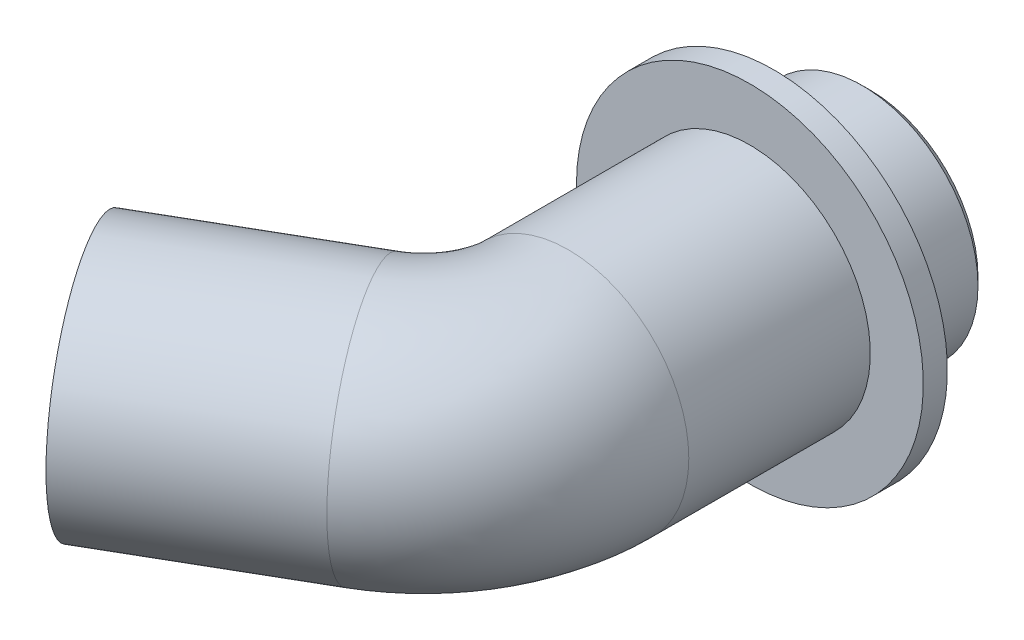
from build123d import *

# Parameters (mm, degrees)
SKETCH_1_R          = 25
SKETCH_1_R_2        = 15
EXTRUDE_START       = -20
SKETCH_3_R          = 36
SKETCH_3_R_2        = 25
EXTRUDE_2_DEPTH     = 5
SKETCH_4_W          = 10
SKETCH_4_H          = 4
CUT_EXTRUDE_1_REACH = 133.651
SKETCH_5_R          = 25
SKETCH_5_R_2        = 24
CHAMFER_1_SIZE      = 1.648


with BuildPart() as part:
    # По траектории1: sweep along a path in Эскиз2
    with BuildLine(Plane(origin=(0, 0, 0), x_dir=(1, 0, 0), z_dir=(0, 1, 0))) as sweep_1_path:
        Line((0, 0), (0, -62.679491924))
        ThreePointArc((0, -62.679491924), (-4.019237886, -77.679491924), (-15, -88.660254038))
        Line((-15, -88.660254038), (-51.961524227, -110))
    # Эскиз1 → По траектории1 (sweep)
    with BuildSketch(Plane.XY):
        Circle(SKETCH_1_R)
        Circle(SKETCH_1_R_2, mode=Mode.SUBTRACT)
    sweep(path=sweep_1_path.line)

    # Эскиз3 → Бобышка-Вытянуть2 (add)
    with BuildSketch(Plane(origin=(0, 0, 0), x_dir=(-1, 0, 0), z_dir=(0, 0, -1)).offset(EXTRUDE_START)):
        Circle(SKETCH_3_R)
        Circle(SKETCH_3_R_2, mode=Mode.SUBTRACT)
    extrude(amount=-EXTRUDE_2_DEPTH)

    # Эскиз4 → Вырез-Повернуть1 (revolve, cut)
    with BuildSketch(Plane(origin=(0, 0, 0), x_dir=(1, 0, 0), z_dir=(0, 1, 0))):
        with Locations((27, -18)):
            Rectangle(SKETCH_4_W, SKETCH_4_H)
    revolve(axis=Axis((0, 0, 0), (0, 0, 1)), mode=Mode.SUBTRACT)

    # Эскиз5 → Вырез-Вытянуть1 (cut, up to next)
    with BuildSketch(Plane(origin=(0, 0, 0), x_dir=(-1, 0, 0), z_dir=(0, 0, -1)), mode=Mode.PRIVATE) as cut_extrude_1_sk1:
        Circle(SKETCH_5_R)
        Circle(SKETCH_5_R_2, mode=Mode.SUBTRACT)
    cut_extrude_1_tool1 = extrude(cut_extrude_1_sk1.sketch, amount=-CUT_EXTRUDE_1_REACH, mode=Mode.PRIVATE) & part.part
    add(cut_extrude_1_tool1.solids().sort_by_distance((24.292893, 0, 0))[0], mode=Mode.SUBTRACT)

    # Фаска1
    chamfer_1_edges = [part.edges().sort_by_distance(p)[0] for p in [
        (24, 0, 0),
    ]]
    chamfer(chamfer_1_edges, length=CHAMFER_1_SIZE)


solid = part.part
